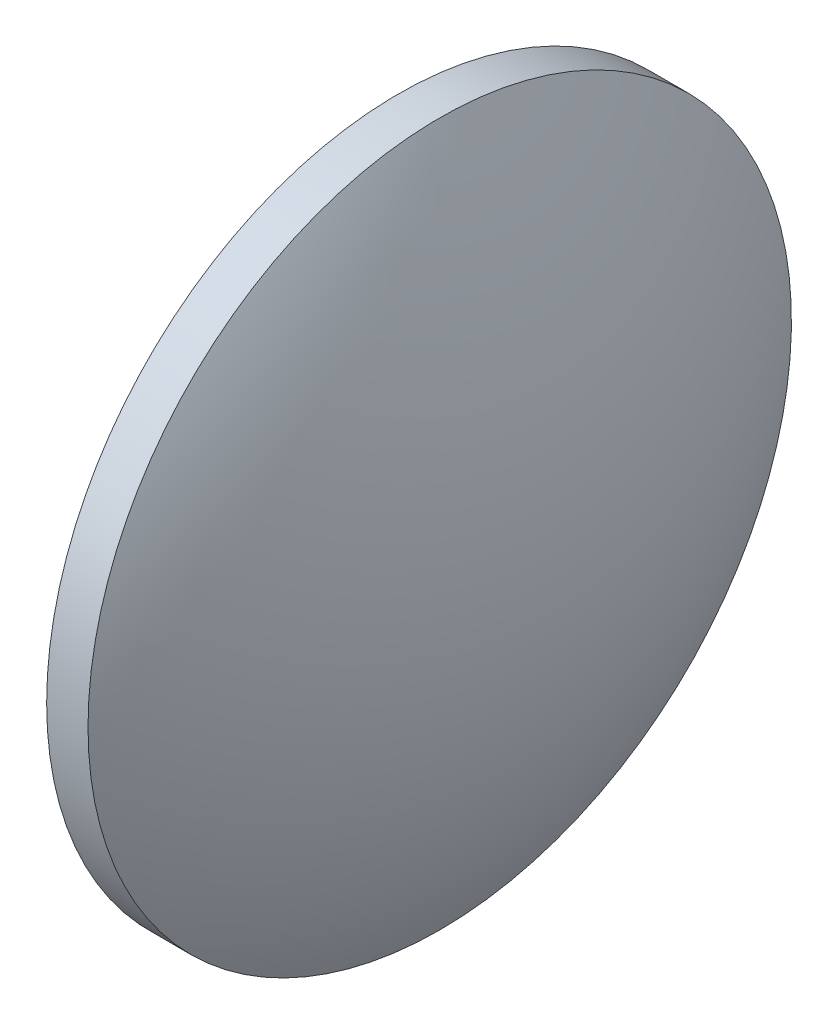
from build123d import *


with BuildPart() as part:
    # 草图1 → 旋转1 (revolve)
    with BuildSketch(Plane.XY, mode=Mode.PRIVATE) as revolve_1_sk:
        with BuildLine():
            Line((554.865777541, 36.893709081), (554.865777541, 49.393709081))
            Line((554.865777541, 49.393709081), (556.335777541, 49.393709081))
            ThreePointArc((556.335777541, 49.393709081), (558.745230301, 43.348995674), (559.565777541, 36.893709081))
            Line((559.565777541, 36.893709081), (554.865777541, 36.893709081))
        make_face()
    revolve(revolve_1_sk.sketch.rotate(Axis((552.500161639, 36.893709081, 0), (1, 0, 0)), 180), axis=Axis((552.500161639, 36.893709081, 0), (1, 0, 0)))  # turned: the seam where the file's is


solid = part.part
